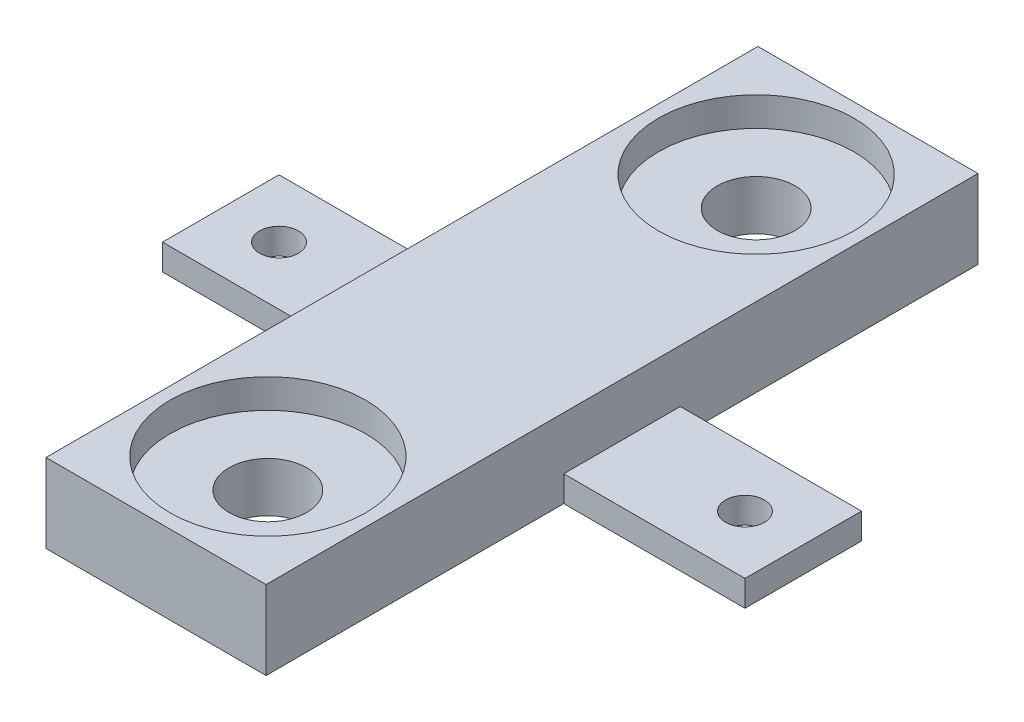
from build123d import *

# Parameters (mm, degrees)
SKETCH1_W           = 17
SKETCH1_H           = 55
SKETCH1_R           = 7.55
SKETCH1_W_2         = 14
SKETCH1_H_2         = 9
SKETCH1_R_2         = 1.5
BOSS_EXTRUDE1_DEPTH = 2
BOSS_EXTRUDE2_START = 2
SKETCH1_4_W         = 17
SKETCH1_4_H         = 55
SKETCH1_4_R         = 7.55
BOSS_EXTRUDE2_DEPTH = 1.838
BOSS_EXTRUDE3_START = 3.838
SKETCH1_5_W         = 17
SKETCH1_5_H         = 55
SKETCH1_5_R         = 7.55
BOSS_EXTRUDE3_DEPTH = 2.25
SKETCH3_R           = 3
CUT_EXTRUDE1_DEPTH  = 7.088


with BuildPart() as part:
    # Sketch1 → Boss-Extrude1 (new body)
    with BuildSketch(Plane(origin=(0, 0, 0), x_dir=(1, 0, 0), z_dir=(0, 1, 0))):
        Rectangle(SKETCH1_W, SKETCH1_H)
        with Locations((0, -18.8625)):
            Circle(SKETCH1_R, mode=Mode.SUBTRACT)
        with Locations((0, 18.8625)):
            Circle(SKETCH1_R, mode=Mode.SUBTRACT)
        with Locations((15.5, 0)):
            Rectangle(SKETCH1_W_2, SKETCH1_H_2)
        with Locations((18, 0)):
            Circle(SKETCH1_R_2, mode=Mode.SUBTRACT)
        with Locations((-15.5, 0)):
            Rectangle(SKETCH1_W_2, SKETCH1_H_2)
        with Locations((-18, 0)):
            Circle(SKETCH1_R_2, mode=Mode.SUBTRACT)
        with Locations((0, -18.8625)):
            Circle(SKETCH1_R)
        with Locations((0, 18.8625)):
            Circle(SKETCH1_R)
    extrude(amount=BOSS_EXTRUDE1_DEPTH)

    # Sketch1_4 → Boss-Extrude2 (add)
    with BuildSketch(Plane(origin=(0, 0, 0), x_dir=(1, 0, 0), z_dir=(0, 1, 0)).offset(BOSS_EXTRUDE2_START)):
        Rectangle(SKETCH1_4_W, SKETCH1_4_H)
        with Locations((0, -18.8625)):
            Circle(SKETCH1_4_R, mode=Mode.SUBTRACT)
        with Locations((0, 18.8625)):
            Circle(SKETCH1_4_R, mode=Mode.SUBTRACT)
        with Locations((0, -18.8625)):
            Circle(SKETCH1_4_R)
        with Locations((0, 18.8625)):
            Circle(SKETCH1_4_R)
    extrude(amount=BOSS_EXTRUDE2_DEPTH)

    # Sketch1_5 → Boss-Extrude3 (add)
    with BuildSketch(Plane(origin=(0, 0, 0), x_dir=(1, 0, 0), z_dir=(0, 1, 0)).offset(BOSS_EXTRUDE3_START)):
        Rectangle(SKETCH1_5_W, SKETCH1_5_H)
        with Locations((0, -18.8625)):
            Circle(SKETCH1_5_R, mode=Mode.SUBTRACT)
        with Locations((0, 18.8625)):
            Circle(SKETCH1_5_R, mode=Mode.SUBTRACT)
    extrude(amount=BOSS_EXTRUDE3_DEPTH)

    # Sketch3 → Cut-Extrude1 (cut, through all)
    with BuildSketch(Plane.XZ):
        with Locations((0, -18.8625)):
            Circle(SKETCH3_R)
        with Locations((0, 18.8625)):
            Circle(SKETCH3_R)
    extrude(amount=-CUT_EXTRUDE1_DEPTH, mode=Mode.SUBTRACT)


solid = part.part
